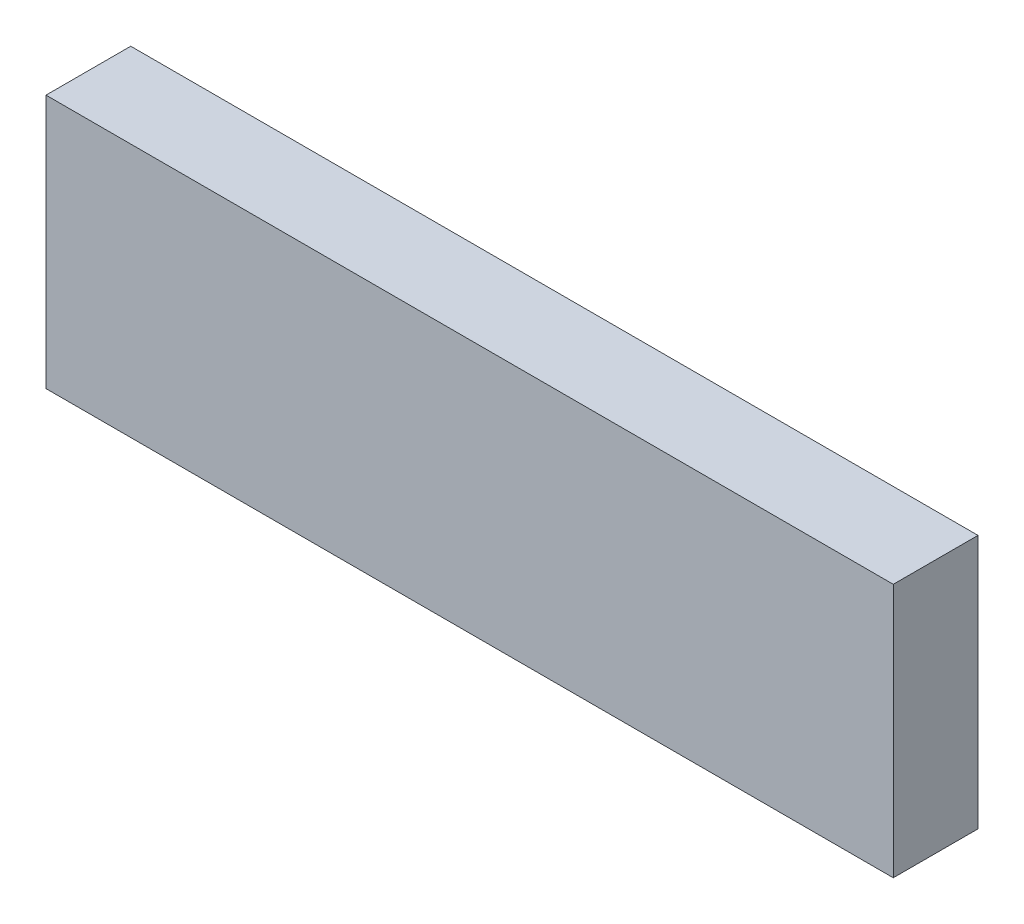
from build123d import *

# Parameters (mm, degrees)
SKETCH1_W           = 63.5
SKETCH1_H           = 19.05
BOSS_EXTRUDE1_DEPTH = 6.35


with BuildPart() as part:
    # Sketch1 → Boss-Extrude1 (new body)
    with BuildSketch(Plane.XY):
        with Locations((13.843, -0.047625)):
            Rectangle(SKETCH1_W, SKETCH1_H)
    extrude(amount=BOSS_EXTRUDE1_DEPTH)


solid = part.part
